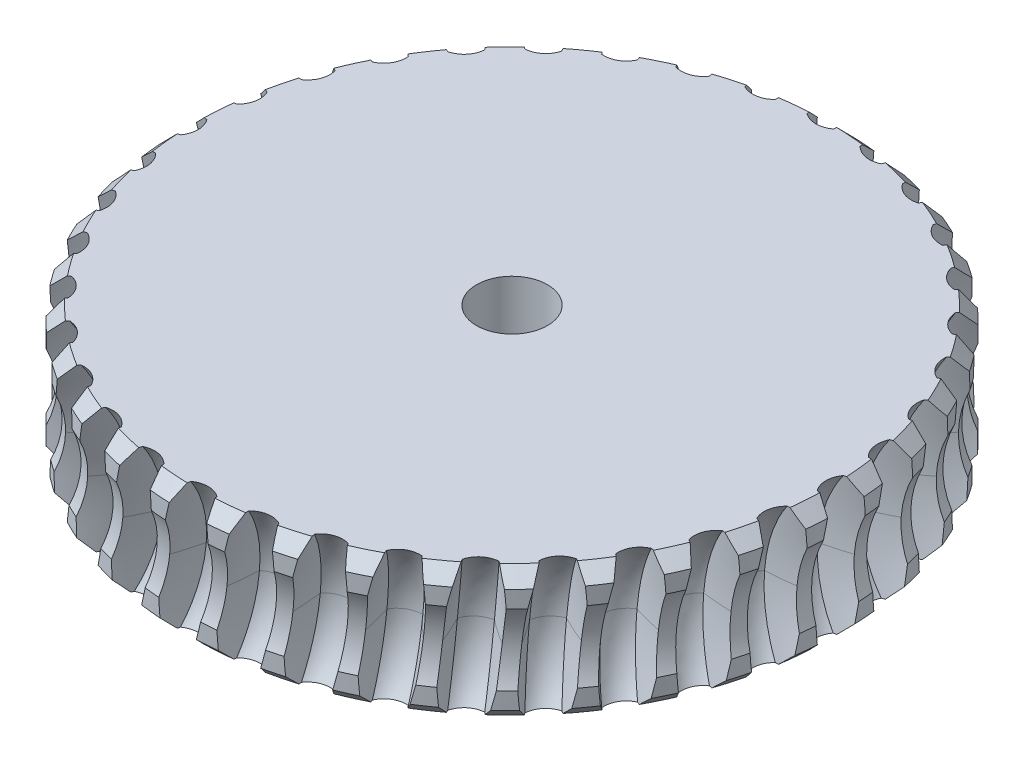
from build123d import *

# Parameters (mm, degrees)
DDSHAFTHOLE_R          = 4.7625
BOSS_EXTRUDE1_DEPTH    = 2.54
BOSS_EXTRUDE2_DEPTH    = 1.905
GEARBOTTOM_R           = 31.856348364
BOSS_EXTRUDE3_DEPTH    = 2.54
SCREWHOLEBOTTOM_R      = 31.856348364
SCREWHOLEBOTTOM_R_2    = 1.5875
BOSS_EXTRUDE4_DEPTH    = 5.08
SCREWHEADBOTTOM_R      = 31.856348364
SCREWHEADBOTTOM_R_2    = 3.429
BOSS_EXTRUDE5_DEPTH    = 5.08
CHAMFER1_SIZE          = 1.27
SKETCH1_R              = 8.255
CUT_SWEEP1_PITCH       = 5.08
CUT_SWEEP1_HEIGHT      = 1.27
CUT_SWEEP1_RADIUS      = 8.255
CUT_SWEEP2_PITCH       = 5.08
CUT_SWEEP2_HEIGHT      = 1.27
CUT_SWEEP2_RADIUS      = 8.255
CUT_SWEEP2_START_ANGLE = -180
CIRPATTERN1_COUNT      = 36


with BuildPart() as part:
    # DDShaftHole → Boss-Extrude1 (new body)
    with BuildSketch(Plane(origin=(0, 0, 0), x_dir=(1, 0, 0), z_dir=(0, 1, 0))):
        with Locations(Location((0, 0, 0), (0, 0, 270))):
            Circle(DDSHAFTHOLE_R)
        with BuildLine():
            Line((2.100065103, 2.38125), (-2.100065103, 2.38125))
            ThreePointArc((-2.100065103, 2.38125), (-3.175, 0), (-2.100065103, -2.38125))
            Line((-2.100065103, -2.38125), (2.100065103, -2.38125))
            ThreePointArc((2.100065103, -2.38125), (3.175, 0), (2.100065103, 2.38125))
        make_face(mode=Mode.SUBTRACT)
    extrude(amount=BOSS_EXTRUDE1_DEPTH)

    # RotationBlock → Boss-Extrude2 (add)
    with BuildSketch(Plane(origin=(0, 2.54, 0), x_dir=(1, 0, 0), z_dir=(0, 1, 0))):
        with BuildLine():
            Line((2.38125, 5.886607549), (2.38125, 4.124445986))
            ThreePointArc((2.38125, 4.124445986), (0, 4.7625), (-2.38125, 4.124445986))
            Line((-2.38125, 4.124445986), (-2.38125, 5.886607549))
            ThreePointArc((-2.38125, 5.886607549), (0, 6.35), (2.38125, 5.886607549))
        make_face()
    extrude(amount=-BOSS_EXTRUDE2_DEPTH)

    # GearBottom → Boss-Extrude3 (add)
    with BuildSketch(Plane(origin=(0, 2.54, 0), x_dir=(1, 0, 0), z_dir=(0, 1, 0))):
        with Locations(Location((0, 0, 0), (0, 0, 270))):
            Circle(GEARBOTTOM_R)
        with BuildLine():
            Line((-2.100065103, 2.38125), (2.100065103, 2.38125))
            ThreePointArc((2.100065103, 2.38125), (3.175, 0), (2.100065103, -2.38125))
            Line((2.100065103, -2.38125), (-2.100065103, -2.38125))
            ThreePointArc((-2.100065103, -2.38125), (-3.175, 0), (-2.100065103, 2.38125))
        make_face(mode=Mode.SUBTRACT)
    extrude(amount=BOSS_EXTRUDE3_DEPTH)

    # ScrewHoleBottom → Boss-Extrude4 (add)
    with BuildSketch(Plane(origin=(0, 5.08, 0), x_dir=(1, 0, 0), z_dir=(0, 1, 0))):
        with Locations(Location((0, 0, 0), (0, 0, 270))):
            Circle(SCREWHOLEBOTTOM_R)
        with Locations(Location((0, 0, 0), (0, 0, 270))):
            Circle(SCREWHOLEBOTTOM_R_2, mode=Mode.SUBTRACT)
    extrude(amount=BOSS_EXTRUDE4_DEPTH)

    # ScrewHeadBottom → Boss-Extrude5 (add)
    with BuildSketch(Plane(origin=(0, 10.16, 0), x_dir=(1, 0, 0), z_dir=(0, 1, 0))):
        with Locations(Location((0, 0, 0), (0, 0, 270))):
            Circle(SCREWHEADBOTTOM_R)
        with Locations(Location((0, 0, 0), (0, 0, 270))):
            Circle(SCREWHEADBOTTOM_R_2, mode=Mode.SUBTRACT)
    extrude(amount=BOSS_EXTRUDE5_DEPTH)

    # Chamfer1
    chamfer1_edges = [part.edges().sort_by_distance(p)[0] for p in [
        (0, 2.54, -31.856348364),
        (0, 15.24, -31.856348364),
    ]]
    chamfer(chamfer1_edges, length=CHAMFER1_SIZE)

    # Sketch1 → Cut-Revolve1 (revolve, cut)
    with BuildSketch(Plane.XY, mode=Mode.PRIVATE) as cut_revolve1_sk:
        with Locations((-39.37, 8.89)):
            Circle(SKETCH1_R)
    revolve(cut_revolve1_sk.sketch.rotate(Axis((0, 3.81, 0), (0, 1, 0)), 270), axis=Axis((0, 3.81, 0), (0, 1, 0)), mode=Mode.SUBTRACT)

    # Cut-Sweep1: sweep along a helix
    with BuildLine() as cut_sweep1_path:
        Helix(CUT_SWEEP1_PITCH, CUT_SWEEP1_HEIGHT, CUT_SWEEP1_RADIUS, center=(-39.37, 8.89, 0), direction=(0, 0, 1))
    # Sketch4 → Cut-Sweep1 (sweep, cut)
    with BuildSketch(Plane(origin=(0, 8.89, 0), x_dir=(1, 0, 0), z_dir=(0, 1, 0))):
        with BuildLine():
            Line((-36.83, 3.81), (-36.83, -3.81))
            Line((-36.83, -3.81), (-35.052, -3.81))
            ThreePointArc((-35.052, -3.81), (-31.757015526, -2.297744168), (-28.280295474, -1.27))
            ThreePointArc((-28.280295474, -1.27), (-27.94, 0), (-28.280295474, 1.27))
            ThreePointArc((-28.280295474, 1.27), (-31.757015526, 2.297744168), (-35.052, 3.81))
            Line((-35.052, 3.81), (-36.83, 3.81))
        make_face()
    cut_sweep1 = sweep(path=cut_sweep1_path.line, is_frenet=True, mode=Mode.SUBTRACT)

    # Cut-Sweep2: sweep along a helix
    with BuildLine() as cut_sweep2_path:
        add(Helix(CUT_SWEEP2_PITCH, CUT_SWEEP2_HEIGHT, CUT_SWEEP2_RADIUS, center=(-39.37, 8.89, 0), direction=(0, 0, -1), mode=Mode.PRIVATE).rotate(Axis((-39.37, 8.89, 0), (0, 0, -1)), CUT_SWEEP2_START_ANGLE))
    # Sketch4_2 → Cut-Sweep2 (sweep, cut)
    with BuildSketch(Plane(origin=(0, 8.89, 0), x_dir=(1, 0, 0), z_dir=(0, 1, 0))):
        with BuildLine():
            Line((-36.83, 3.81), (-36.83, -3.81))
            Line((-36.83, -3.81), (-35.052, -3.81))
            ThreePointArc((-35.052, -3.81), (-31.757015526, -2.297744168), (-28.280295474, -1.27))
            ThreePointArc((-28.280295474, -1.27), (-27.94, 0), (-28.280295474, 1.27))
            ThreePointArc((-28.280295474, 1.27), (-31.757015526, 2.297744168), (-35.052, 3.81))
            Line((-35.052, 3.81), (-36.83, 3.81))
        make_face()
    cut_sweep2 = sweep(path=cut_sweep2_path.line, is_frenet=True, mode=Mode.SUBTRACT)

    # CirPattern1: Cut-Sweep1, Cut-Sweep2 ×36 about axis
    cirpattern1_axis = Axis((0, 15.24, 0), (0, 1, 0))
    add([cut_sweep1.rotate(cirpattern1_axis, i * 360 / CIRPATTERN1_COUNT) for i in range(1, CIRPATTERN1_COUNT)], mode=Mode.SUBTRACT)
    add([cut_sweep2.rotate(cirpattern1_axis, i * 360 / CIRPATTERN1_COUNT) for i in range(1, CIRPATTERN1_COUNT)], mode=Mode.SUBTRACT)


solid = part.part
